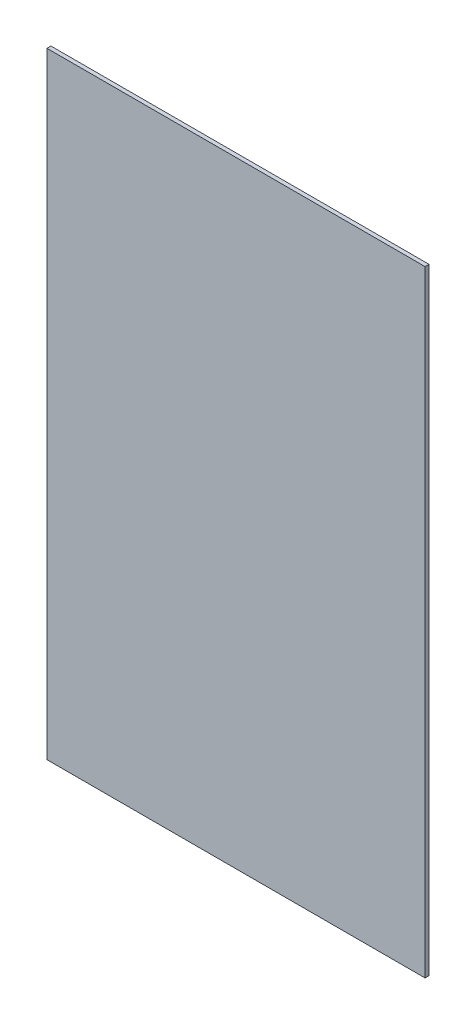
from build123d import *

# Parameters (mm, degrees)
ESQUISSE1_W        = 286
ESQUISSE1_H        = 466
BOSS_EXTRU_1_DEPTH = 3


with BuildPart() as part:
    # Esquisse1 → Boss.-Extru.1 (new body)
    with BuildSketch(Plane.XY):
        with Locations((75.445936041, -166.343742621)):
            Rectangle(ESQUISSE1_W, ESQUISSE1_H)
    extrude(amount=BOSS_EXTRU_1_DEPTH)


solid = part.part
